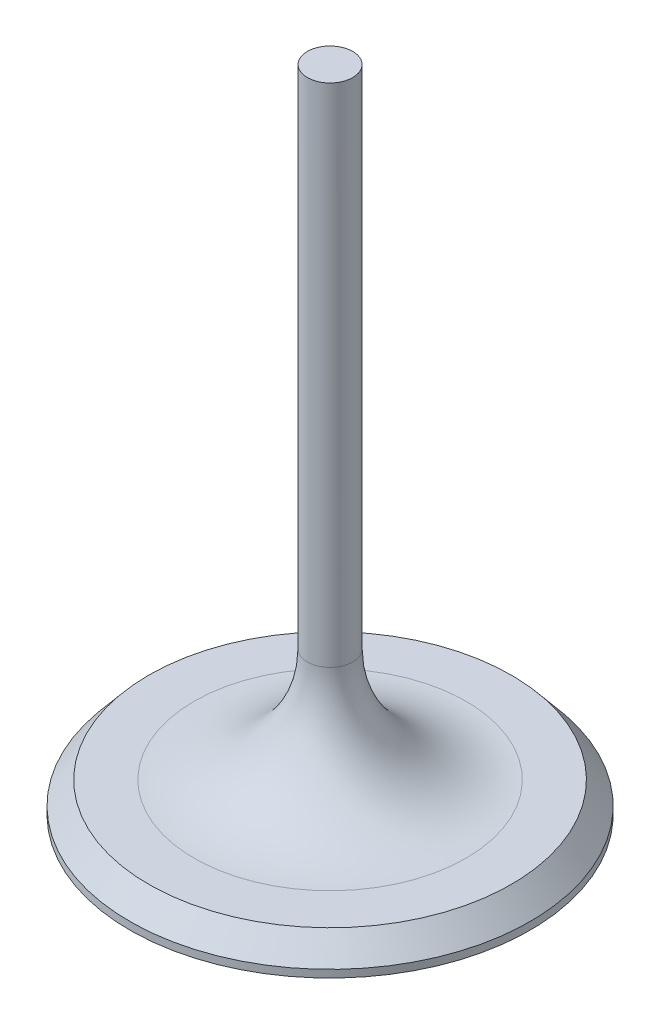
from build123d import *

# Parameters (mm, degrees)
FILLET1_R = 15


with BuildPart() as part:
    # Sketch1 → Revolve1 (revolve)
    with BuildSketch(Plane.XY):
        Polygon((0, 72.092198582), (0, -13.907801418), (26.5, -13.907801418), (26.5, -12.907801418), (24, -9.907801418), (18, -9.907801418), (3, -9.907801418), (3, 5.092198582), (3, 72.092198582), align=None)
    revolve(axis=Axis((0, 72.092198582, 0), (0, -1, 0)))

    # Fillet1
    fillet1_edges = [part.edges().sort_by_distance(p)[0] for p in [
        (-3, -9.907801418, 0),
    ]]
    fillet(fillet1_edges, radius=FILLET1_R)


solid = part.part
